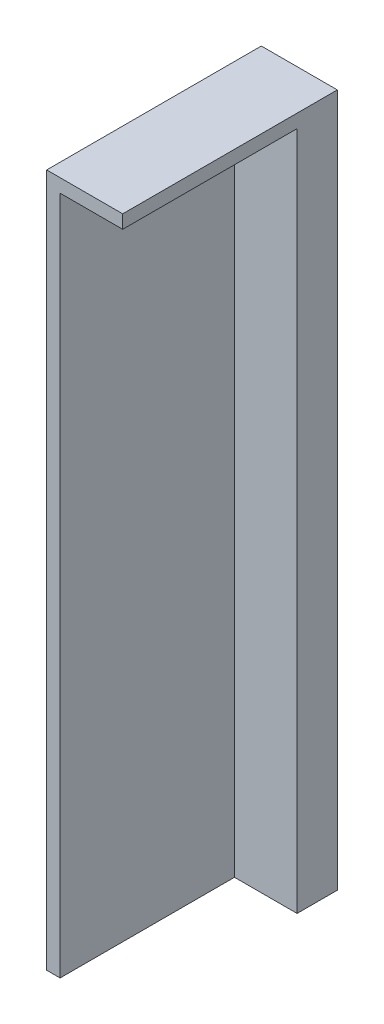
from build123d import *

# Parameters (mm, degrees)
SKETCH1_W           = 4.25
SKETCH1_H           = 38.75
BOSS_EXTRUDE1_DEPTH = 12
SKETCH2_W           = 9.75
SKETCH2_H           = 38
CUT_EXTRUDE1_DEPTH  = 3.5


with BuildPart() as part:
    # Sketch1 → Boss-Extrude1 (new body)
    with BuildSketch(Plane.XY):
        Rectangle(SKETCH1_W, SKETCH1_H)
    extrude(amount=BOSS_EXTRUDE1_DEPTH)

    # Sketch2 → Cut-Extrude1 (cut)
    with BuildSketch(Plane.ZY.offset(2.125)):
        with Locations((7.125, -0.375)):
            Rectangle(SKETCH2_W, SKETCH2_H)
    extrude(amount=-CUT_EXTRUDE1_DEPTH, mode=Mode.SUBTRACT)


with BuildPart() as body_2:
    # Mirror2: mirrored copy
    add(part.part.mirror(Plane.ZY.offset(12.125)))


solid = body_2.part
